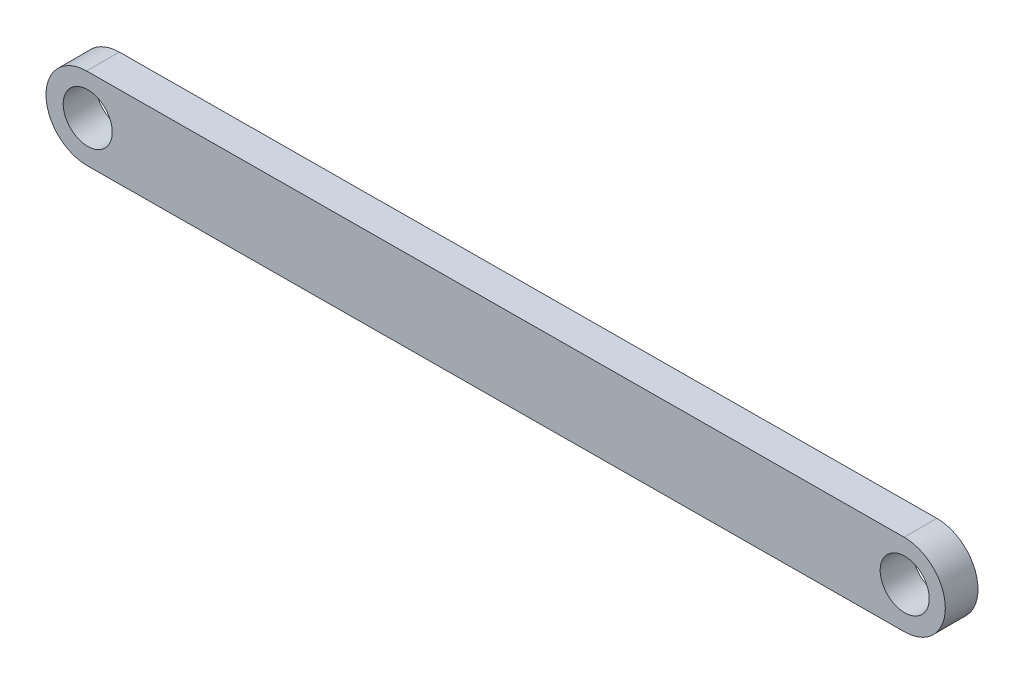
from build123d import *

# Parameters (mm, degrees)
SKETCH1_R           = 1.5
BOSS_EXTRUDE1_DEPTH = 2


with BuildPart() as part:
    # Sketch1 → Boss-Extrude1 (new body)
    with BuildSketch(Plane.XY):
        with BuildLine():
            Line((0.010283133, 2.436111241), (50.010283133, 2.740370876))
            ThreePointArc((50.010283133, 2.740370876), (52.525449548, 0.255629861), (50.040708533, -2.259536553))
            Line((50.040708533, -2.259536553), (0.040708533, -2.563796188))
            ThreePointArc((0.040708533, -2.563796188), (-2.474457881, -0.079055174), (0.010283133, 2.436111241))
        make_face()
        with Locations((0.076973552, -0.02313692)):
            Circle(SKETCH1_R, mode=Mode.SUBTRACT)
        with Locations((50.042345358, 0.254710298)):
            Circle(SKETCH1_R, mode=Mode.SUBTRACT)
    extrude(amount=BOSS_EXTRUDE1_DEPTH)


solid = part.part
